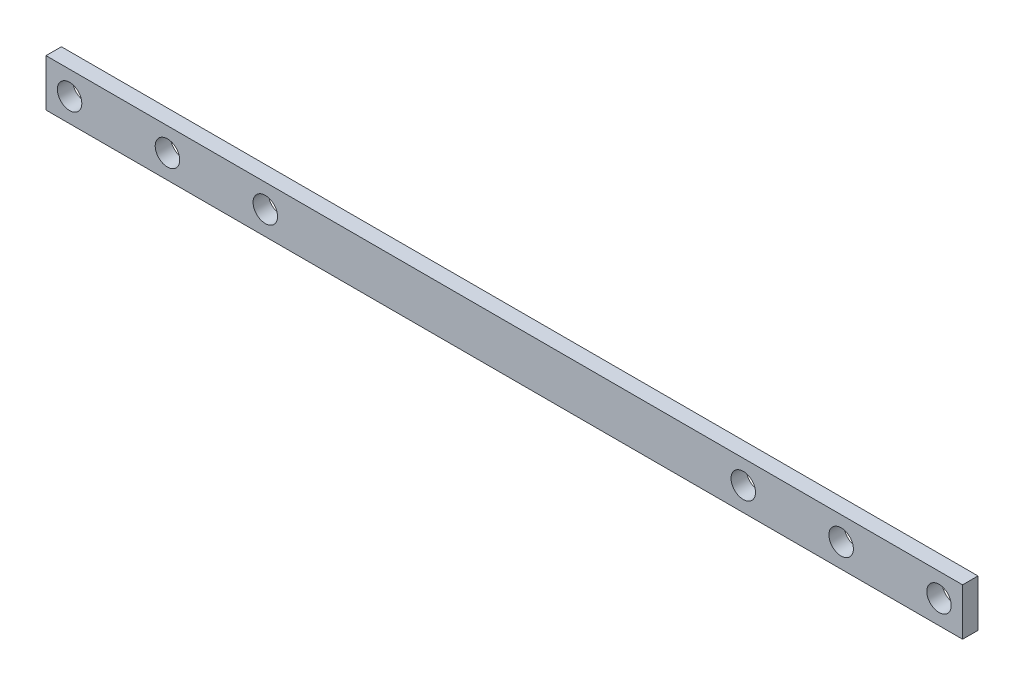
from build123d import *

# Parameters (mm, degrees)
SKETCH2_W           = 118.945
SKETCH2_H           = 6.12
SKETCH2_R           = 1.5875
BOSS_EXTRUDE1_DEPTH = 2


with BuildPart() as part:
    # Sketch2 → Boss-Extrude1 (new body)
    with BuildSketch(Plane.XY):
        with Locations((-90, 33.1712758)):
            Rectangle(SKETCH2_W, SKETCH2_H)
        with Locations((-146.4125, 33.175)):
            Circle(SKETCH2_R, mode=Mode.SUBTRACT)
        with Locations((-133.7125, 33.175)):
            Circle(SKETCH2_R, mode=Mode.SUBTRACT)
        with Locations((-121.0125, 33.175)):
            Circle(SKETCH2_R, mode=Mode.SUBTRACT)
        with Locations((-58.9875, 33.175)):
            Circle(SKETCH2_R, mode=Mode.SUBTRACT)
        with Locations((-46.2875, 33.175)):
            Circle(SKETCH2_R, mode=Mode.SUBTRACT)
        with Locations((-33.5875, 33.175)):
            Circle(SKETCH2_R, mode=Mode.SUBTRACT)
    extrude(amount=BOSS_EXTRUDE1_DEPTH)


solid = part.part
